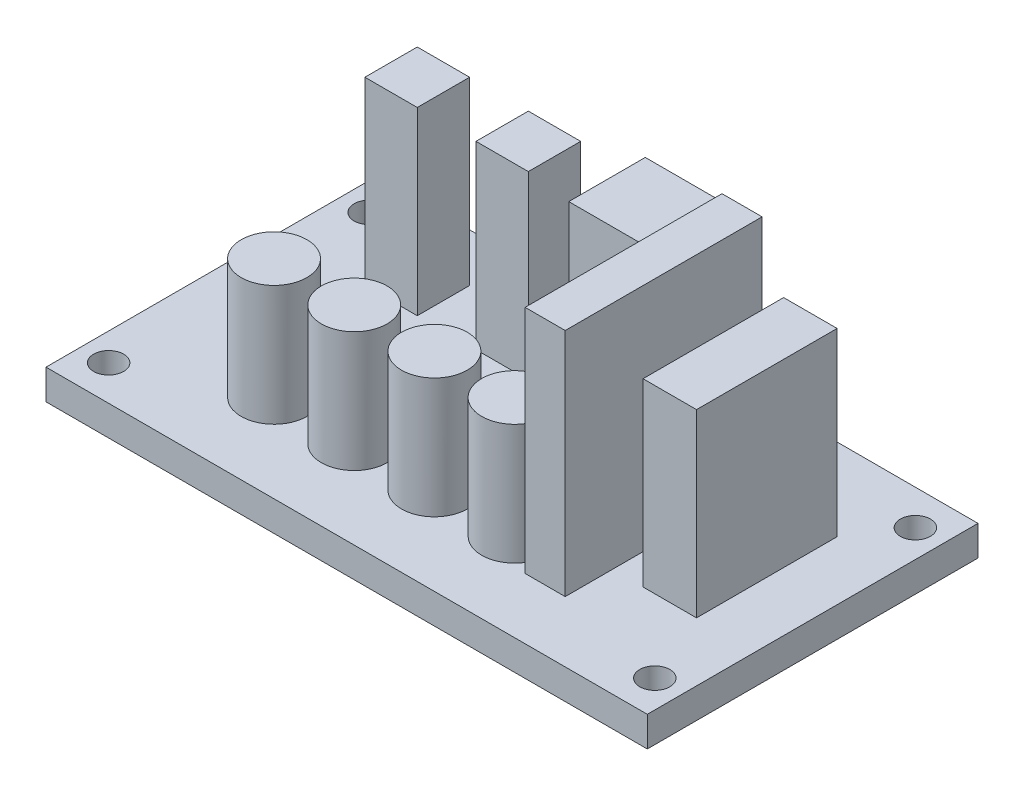
from build123d import *

# Parameters (mm, degrees)
ESQUISSE1_W      = 60
ESQUISSE1_H      = 33
ESQUISSE1_R      = 1.5
EXTRUSION1_DEPTH = 3
ESQUISSE2_W      = 7.634201779
ESQUISSE2_H      = 7.63420178
ESQUISSE2_W_2    = 5.337752956
ESQUISSE2_H_2    = 14.027301674
ESQUISSE2_W_3    = 5.224355128
ESQUISSE2_H_3    = 5.224355128
EXTRUSION2_DEPTH = 18
ESQUISSE3_R      = 3.279080348
EXTRUSION3_DEPTH = 12
ESQUISSE4_W      = 4
ESQUISSE4_H      = 19.646099489
EXTRUSION4_DEPTH = 23


with BuildPart() as part:
    # Esquisse1 → Extrusion1 (new body)
    with BuildSketch(Plane(origin=(0, 0, 0), x_dir=(1, 0, 0), z_dir=(0, 1, 0))):
        with Locations((30, 16.5)):
            Rectangle(ESQUISSE1_W, ESQUISSE1_H)
        with Locations((2.75, 29.5)):
            Circle(ESQUISSE1_R, mode=Mode.SUBTRACT)
        with Locations((57.25, 29.5)):
            Circle(ESQUISSE1_R, mode=Mode.SUBTRACT)
        with Locations((57.25, 3.5)):
            Circle(ESQUISSE1_R, mode=Mode.SUBTRACT)
        with Locations((2.75, 3.5)):
            Circle(ESQUISSE1_R, mode=Mode.SUBTRACT)
    extrude(amount=EXTRUSION1_DEPTH)

    # Esquisse2 → Extrusion2 (add)
    with BuildSketch(Plane(origin=(0, 3, 0), x_dir=(1, 0, 0), z_dir=(0, 1, 0))):
        with Locations((33.593446124, 26.205676479)):
            Rectangle(ESQUISSE2_W, ESQUISSE2_H)
        with Locations((51.457386868, 17.801055276)):
            Rectangle(ESQUISSE2_W_2, ESQUISSE2_H_2)
        with Locations((11.46939236, 25.577155504)):
            Rectangle(ESQUISSE2_W_3, ESQUISSE2_H_3)
        with Locations((22.552159567, 25.577155504)):
            Rectangle(ESQUISSE2_W_3, ESQUISSE2_H_3)
    extrude(amount=EXTRUSION2_DEPTH)

    # Esquisse3 → Extrusion3 (add)
    with BuildSketch(Plane(origin=(0, 3, 0), x_dir=(1, 0, 0), z_dir=(0, 1, 0))):
        with Locations((14, 8.756763264)):
            Circle(ESQUISSE3_R)
        with Locations((22, 8.756763264)):
            Circle(ESQUISSE3_R)
        with Locations((30, 8.756763264)):
            Circle(ESQUISSE3_R)
        with Locations((38, 8.756763264)):
            Circle(ESQUISSE3_R)
    extrude(amount=EXTRUSION3_DEPTH)

    # Esquisse4 → Extrusion4 (add)
    with BuildSketch(Plane(origin=(0, 3, 0), x_dir=(1, 0, 0), z_dir=(0, 1, 0))):
        with Locations((43.737455539, 15.895279312)):
            Rectangle(ESQUISSE4_W, ESQUISSE4_H)
    extrude(amount=EXTRUSION4_DEPTH)


solid = part.part
